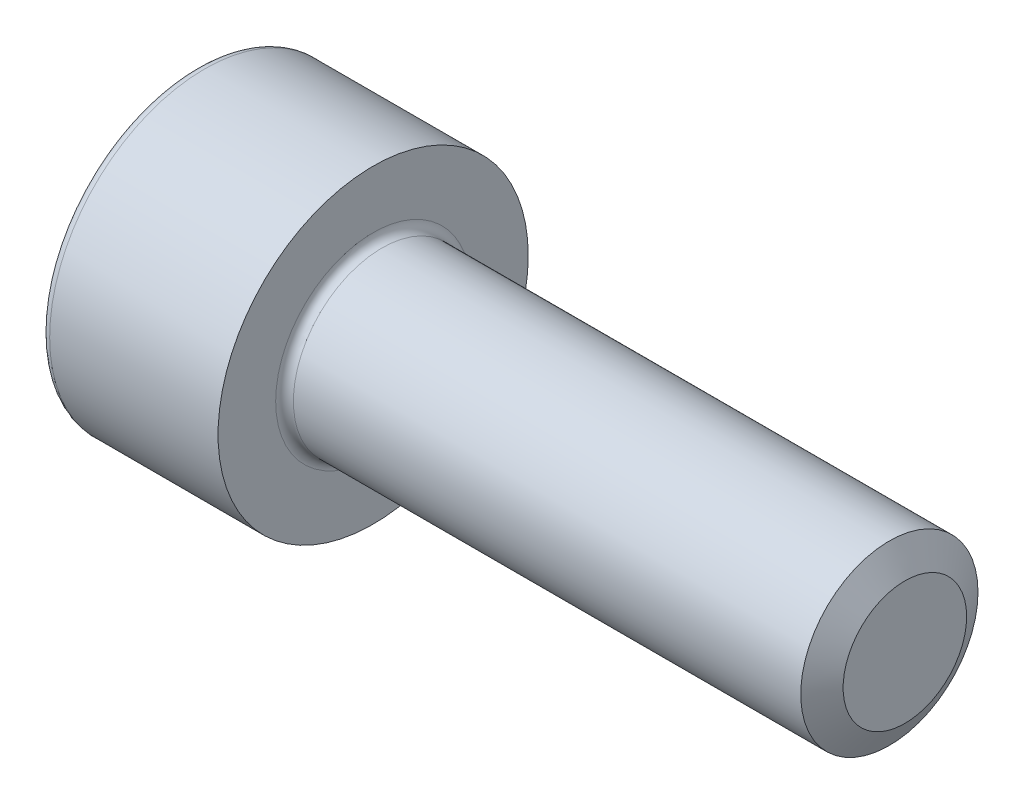
from build123d import *

# Parameters (mm, degrees)
SKETCH_1_W          = 4
SKETCH_1_H          = 3.5
SKETCH_2_R          = 2
EXTRUDE_1_DEPTH     = 12
CUT_EXTRUDE_1_DEPTH = 2
CHAMFER_1_SIZE      = 0.6062
CHAMFER_1_SIZE2     = 0.35
FILLET_1_R          = 0.2


with BuildPart() as part:
    # 草图1 → 旋转1 (revolve)
    with BuildSketch(Plane.XY):
        with Locations((2, 1.75)):
            Rectangle(SKETCH_1_W, SKETCH_1_H)
    revolve(axis=Axis((0, 0, 0), (1, 0, 0)))

    # 草图2 → 凸台-拉伸1 (add)
    with BuildSketch(Plane(origin=(4, 0, 0), x_dir=(0, 0, -1), z_dir=(1, 0, 0))):
        Circle(SKETCH_2_R)
    extrude(amount=EXTRUDE_1_DEPTH)

    # 草图3 → 切除-拉伸1 (cut)
    with BuildSketch(Plane.ZY):
        Polygon((0, 1.72), (-1.489563695, 0.86), (-1.489563695, -0.86), (0, -1.72), (1.489563695, -0.86), (1.489563695, 0.86), align=None)
    extrude(amount=-CUT_EXTRUDE_1_DEPTH, mode=Mode.SUBTRACT)

    # 倒角1
    chamfer_1_edges = [part.edges().sort_by_distance(p)[0] for p in [
        (16, 0, 2),
    ]]
    chamfer_1_side = [part.faces().sort_by_distance(p)[0] for p in [
        (16, 0, 0),
    ]]
    chamfer(chamfer_1_edges, length=CHAMFER_1_SIZE, length2=CHAMFER_1_SIZE2, reference=chamfer_1_side[0])

    # 圆角1
    fillet_1_edges = [part.edges().sort_by_distance(p)[0] for p in [
        (0, -3.5, 0),
        (4, 0, 2),
    ]]
    fillet(fillet_1_edges, radius=FILLET_1_R)


solid = part.part
